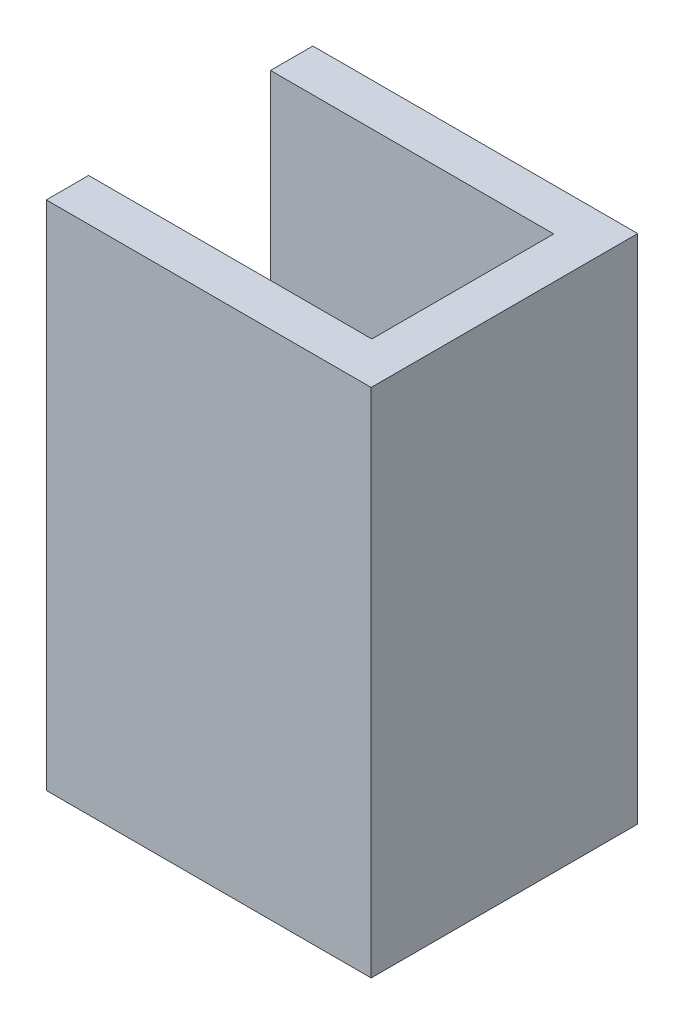
from build123d import *

# Parameters (mm, degrees)
SKETCH2_W               = 16
SKETCH2_H               = 30.7
BOSS_EXTRUDE1_DEPTH     = 9.75
SKETCH3_W               = 10.92
SKETCH3_H               = 29.1
CUT_EXTRUDE1_DEPTH      = 17
SKETCH4_W               = 10.92
SKETCH4_H               = 1.6
CUT_EXTRUDE2_DEPTH      = 5.08
SKETCH5_R               = 2
HOLE_FOR_ACTUATOR_DEPTH = 1.6


with BuildPart() as part:
    # Sketch2 → Boss-Extrude1 (new body, symmetric)
    with BuildSketch(Plane(origin=(0, 0, 0), x_dir=(0, 0, -1), z_dir=(1, 0, 0))):
        Rectangle(SKETCH2_W, SKETCH2_H)
    extrude(amount=BOSS_EXTRUDE1_DEPTH, both=True)

    # Sketch3 → Cut-Extrude1 (cut)
    with BuildSketch(Plane.ZY.offset(9.75)):
        with Locations((0, 0.8)):
            Rectangle(SKETCH3_W, SKETCH3_H)
    extrude(amount=-CUT_EXTRUDE1_DEPTH, mode=Mode.SUBTRACT)

    # Sketch4 → Cut-Extrude2 (cut)
    with BuildSketch(Plane.ZY.offset(9.75)):
        with Locations((0, -14.55)):
            Rectangle(SKETCH4_W, SKETCH4_H)
    extrude(amount=-CUT_EXTRUDE2_DEPTH, mode=Mode.SUBTRACT)

    # Sketch5 → Hole for Actuator (cut)
    with BuildSketch(Plane.XZ.offset(15.35)):
        with Locations((1.27, 0)):
            Circle(SKETCH5_R)
    extrude(amount=-HOLE_FOR_ACTUATOR_DEPTH, mode=Mode.SUBTRACT)


solid = part.part
